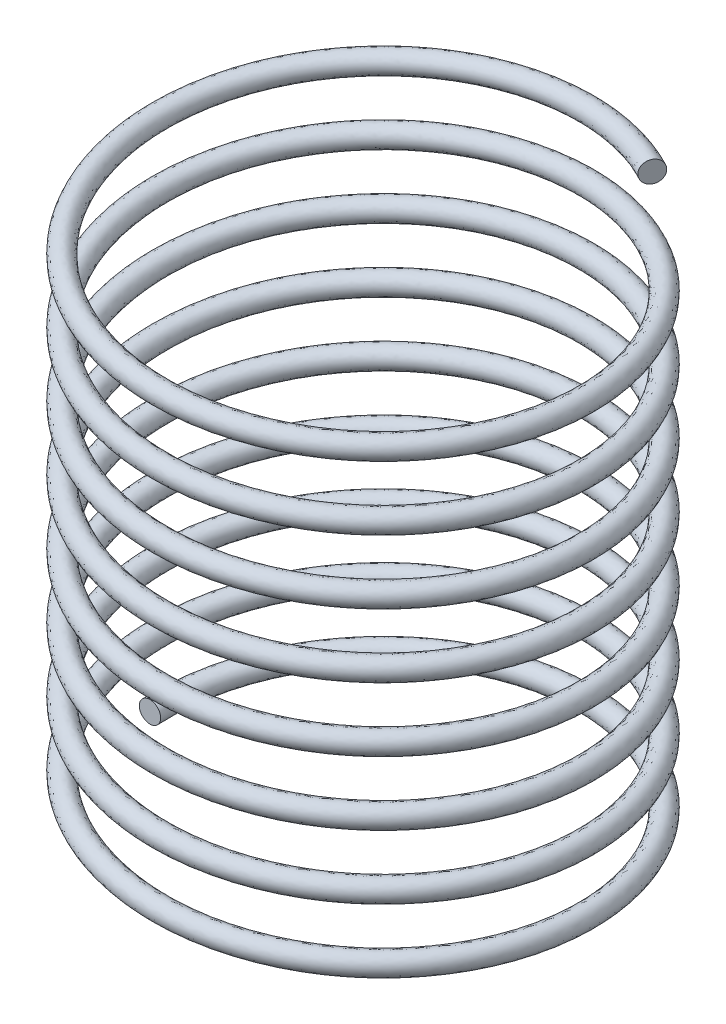
from build123d import *

# Parameters (mm, degrees)
SWEEP1_PITCH       = 3
SWEEP1_HEIGHT      = 24.99
SWEEP1_RADIUS      = 10
SWEEP1_START_ANGLE = -90
SKETCH4_R          = 0.5


with BuildPart() as part:
    # Sweep1: sweep along a helix
    with BuildLine() as sweep1_path:
        add(Helix(SWEEP1_PITCH, SWEEP1_HEIGHT, SWEEP1_RADIUS, center=(0, 0, 0), direction=(0, 1, 0), lefthand=True, mode=Mode.PRIVATE).rotate(Axis((0, 0, 0), (0, 1, 0)), SWEEP1_START_ANGLE))
    # Sketch4 → Sweep1 (sweep)
    with BuildSketch(Plane.XY):
        with Locations((-10, 0)):
            Circle(SKETCH4_R)
    sweep(path=sweep1_path.line, is_frenet=True)


solid = part.part
